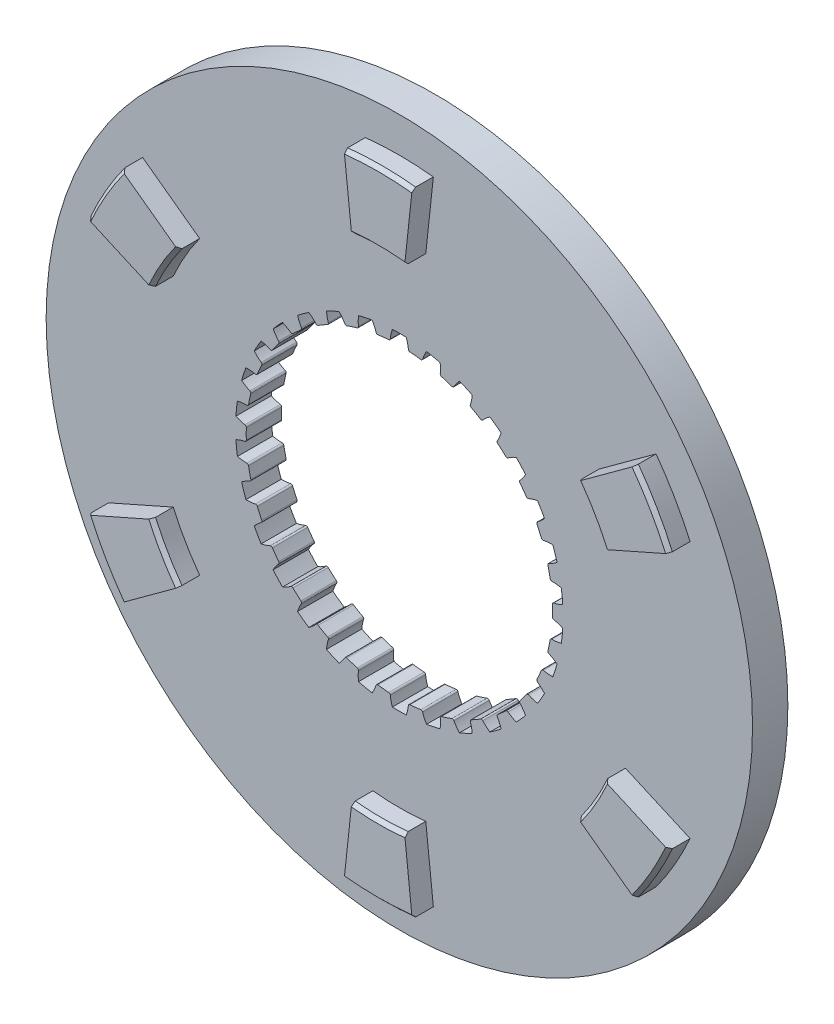
from build123d import *

# Parameters (mm, degrees)
SKETCH1_R                = 100
BOSS_EXTRUDE1_DEPTH      = 10
BOSS_EXTRUDE2_DEPTH      = 6
CHAMFER1_SIZE            = 1
CUT_EXTRUDE2_DEPTH       = 11
SKETCH4_R                = 43.35
CUT_EXTRUDE3_DEPTH       = 11.0000001
FILLET2_R                = 0.48
CIRPATTERN3_COUNT        = 30
FILLET2_OF_CIRPATTERN3_R = 0.48
CHAMFER1_OF_MIRROR1_SIZE = 1


with BuildPart() as part:
    # Sketch1 → Boss-Extrude1 (new body)
    with BuildSketch(Plane.XY):
        Circle(SKETCH1_R)
    extrude(amount=BOSS_EXTRUDE1_DEPTH)

    # Sketch2 → Boss-Extrude2 (add)
    with BuildSketch(Plane.XY.offset(10)):
        with BuildLine():
            ThreePointArc((-7.489441028, 69.598191593), (0, 70), (7.489441028, 69.598191593))
            Line((7.489441028, 69.598191593), (9.629281322, 89.483389192))
            ThreePointArc((9.629281322, 89.483389192), (0, 90), (-9.629281322, 89.483389192))
            Line((-9.629281322, 89.483389192), (-7.489441028, 69.598191593))
        make_face()
        with BuildLine():
            ThreePointArc((56.529081463, 41.285141987), (60.621778265, 35), (64.018522492, 28.313049606))
            Line((64.018522492, 28.313049606), (82.309528918, 36.402492351))
            ThreePointArc((82.309528918, 36.402492351), (77.942286341, 45), (72.680247596, 53.080896841))
            Line((72.680247596, 53.080896841), (56.529081463, 41.285141987))
        make_face()
        with BuildLine():
            ThreePointArc((64.018522492, -28.313049606), (60.621778265, -35), (56.529081463, -41.285141987))
            Line((56.529081463, -41.285141987), (72.680247596, -53.080896841))
            ThreePointArc((72.680247596, -53.080896841), (77.942286341, -45), (82.309528918, -36.402492351))
            Line((82.309528918, -36.402492351), (64.018522492, -28.313049606))
        make_face()
        with BuildLine():
            ThreePointArc((7.489441028, -69.598191593), (0, -70), (-7.489441028, -69.598191593))
            Line((-7.489441028, -69.598191593), (-9.629281322, -89.483389192))
            ThreePointArc((-9.629281322, -89.483389192), (0, -90), (9.629281322, -89.483389192))
            Line((9.629281322, -89.483389192), (7.489441028, -69.598191593))
        make_face()
        with BuildLine():
            ThreePointArc((-56.529081463, -41.285141987), (-60.621778265, -35), (-64.018522492, -28.313049606))
            Line((-64.018522492, -28.313049606), (-82.309528918, -36.402492351))
            ThreePointArc((-82.309528918, -36.402492351), (-77.942286341, -45), (-72.680247596, -53.080896841))
            Line((-72.680247596, -53.080896841), (-56.529081463, -41.285141987))
        make_face()
        with BuildLine():
            ThreePointArc((-64.018522492, 28.313049606), (-60.621778265, 35), (-56.529081463, 41.285141987))
            Line((-56.529081463, 41.285141987), (-72.680247596, 53.080896841))
            ThreePointArc((-72.680247596, 53.080896841), (-77.942286341, 45), (-82.309528918, 36.402492351))
            Line((-82.309528918, 36.402492351), (-64.018522492, 28.313049606))
        make_face()
    boss_extrude2 = extrude(amount=BOSS_EXTRUDE2_DEPTH)

    # Chamfer1
    chamfer1_edges = [part.edges().sort_by_distance(p)[0] for p in [
        (-60.621778265, 35, 16),
        (-77.942286341, 45, 16),
        (-60.621778265, -35, 16),
        (-77.942286341, -45, 16),
        (0, -70, 16),
        (0, -90, 16),
        (60.621778265, -35, 16),
        (77.942286341, -45, 16),
        (60.621778265, 35, 16),
        (77.942286341, 45, 16),
        (0, 70, 16),
        (0, 90, 16),
    ]]
    chamfer(chamfer1_edges, length=CHAMFER1_SIZE)

    # Sketch3 → Cut-Extrude2 (cut, through all)
    with BuildSketch(Plane.XY.offset(10)):
        with BuildLine():
            ThreePointArc((-2.569152136, 43.273802205), (0, 43.35), (2.569152136, 43.273802205))
            add(Edge.make_bspline(
                [(2.569152136, 43.273802205), (2.572726023, 43.412227185), (2.543991205, 43.965573738), (2.368085897, 44.988630421), (2.123800311, 45.851335318), (1.972528188, 46.308008298)],
                knots=[0, 0, 0, 0, 0.111136745, 0.444343171, 0.830550853, 0.830550853, 0.830550853, 0.830550853], degree=3))
            ThreePointArc((1.972528188, 46.308008298), (0, 46.35), (-1.972528188, 46.308008298))
            add(Edge.make_bspline(
                [(-2.569152136, 43.273802205), (-2.572726023, 43.412227185), (-2.543991205, 43.965573738), (-2.368085897, 44.988630421), (-2.123800311, 45.851335318), (-1.972528188, 46.308008298)],
                knots=[0, 0, 0, 0, 0.111136745, 0.444343171, 0.830550853, 0.830550853, 0.830550853, 0.830550853], degree=3))
        make_face()
    cut_extrude2 = extrude(amount=-CUT_EXTRUDE2_DEPTH, mode=Mode.SUBTRACT)

    # Sketch4 → Cut-Extrude3 (cut, through all)
    with BuildSketch(Plane.XY.offset(10)):
        Circle(SKETCH4_R)
    extrude(amount=-CUT_EXTRUDE3_DEPTH, mode=Mode.SUBTRACT)

    # Fillet2
    fillet2_edges = [part.edges().sort_by_distance(p)[0] for p in [
        (2.569152136, 43.273802205, 5),
        (-2.569152136, 43.273802205, 5),
    ]]
    fillet(fillet2_edges, radius=FILLET2_R)

    # CirPattern3: Cut-Extrude2 ×30 about axis
    cirpattern3_axis = Axis((0, 0, 0), (0, 0, 1))
    for i in range(1, CIRPATTERN3_COUNT):
        add(cut_extrude2.rotate(cirpattern3_axis, i * 360 / CIRPATTERN3_COUNT), mode=Mode.SUBTRACT)

    # Fillet2 of CirPattern3
    fillet2_of_cirpattern3_edges = [part.edges().sort_by_distance(p)[0] for p in [
        (-6.484119387, 42.862322566, 5),
        (-11.510139383, 41.794009037, 5),
        (-15.254003778, 40.577553755, 5),
        (-19.948078306, 38.487617124, 5),
        (-23.357215007, 36.519351132, 5),
        (-27.514190486, 33.499131659, 5),
        (-30.439603861, 30.865077625, 5),
        (-33.877800514, 27.046573393, 5),
        (-36.19163596, 23.861852119, 5),
        (-38.760788096, 19.411950086, 5),
        (-40.361919901, 15.815749173, 5),
        (-41.949743243, 10.928931412, 5),
        (-42.768194264, 7.078422096, 5),
        (-43.305293314, 1.968265992, 5),
        (-43.305293314, -1.968265992, 5),
        (-42.768194264, -7.078422096, 5),
        (-41.949743243, -10.928931412, 5),
        (-40.361919901, -15.815749173, 5),
        (-38.760788096, -19.411950086, 5),
        (-36.19163596, -23.861852119, 5),
        (-33.877800514, -27.046573393, 5),
        (-30.439603861, -30.865077625, 5),
        (-27.514190486, -33.499131659, 5),
        (-23.357215007, -36.519351132, 5),
        (-19.948078306, -38.487617124, 5),
        (-15.254003778, -40.577553755, 5),
        (-11.510139383, -41.794009037, 5),
        (-6.484119387, -42.862322566, 5),
        (-2.569152136, -43.273802205, 5),
        (2.569152136, -43.273802205, 5),
        (6.484119387, -42.862322566, 5),
        (11.510139383, -41.794009037, 5),
        (15.254003778, -40.577553755, 5),
        (19.948078306, -38.487617124, 5),
        (23.357215007, -36.519351132, 5),
        (27.514190486, -33.499131659, 5),
        (30.439603861, -30.865077625, 5),
        (33.877800514, -27.046573393, 5),
        (36.19163596, -23.861852119, 5),
        (38.760788096, -19.411950086, 5),
        (40.361919901, -15.815749173, 5),
        (41.949743243, -10.928931412, 5),
        (42.768194264, -7.078422096, 5),
        (43.305293314, -1.968265992, 5),
        (43.305293314, 1.968265992, 5),
        (42.768194264, 7.078422096, 5),
        (41.949743243, 10.928931412, 5),
        (40.361919901, 15.815749173, 5),
        (38.760788096, 19.411950086, 5),
        (36.19163596, 23.861852119, 5),
        (33.877800514, 27.046573393, 5),
        (30.439603861, 30.865077625, 5),
        (27.514190486, 33.499131659, 5),
        (23.357215007, 36.519351132, 5),
        (19.948078306, 38.487617124, 5),
        (15.254003778, 40.577553755, 5),
        (11.510139383, 41.794009037, 5),
        (6.484119387, 42.862322566, 5),
    ]]
    fillet(fillet2_of_cirpattern3_edges, radius=FILLET2_OF_CIRPATTERN3_R)

    # Mirror1: Boss-Extrude2 across plane
    add(boss_extrude2.mirror(Plane.XY.offset(5)))

    # Chamfer1 of Mirror1
    chamfer1_of_mirror1_edges = [part.edges().sort_by_distance(p)[0] for p in [
        (-60.621778265, 35, -6),
        (-77.942286341, 45, -6),
        (-60.621778265, -35, -6),
        (-77.942286341, -45, -6),
        (0, -70, -6),
        (0, -90, -6),
        (60.621778265, -35, -6),
        (77.942286341, -45, -6),
        (60.621778265, 35, -6),
        (77.942286341, 45, -6),
        (0, 70, -6),
        (0, 90, -6),
    ]]
    chamfer(chamfer1_of_mirror1_edges, length=CHAMFER1_OF_MIRROR1_SIZE)


solid = part.part
